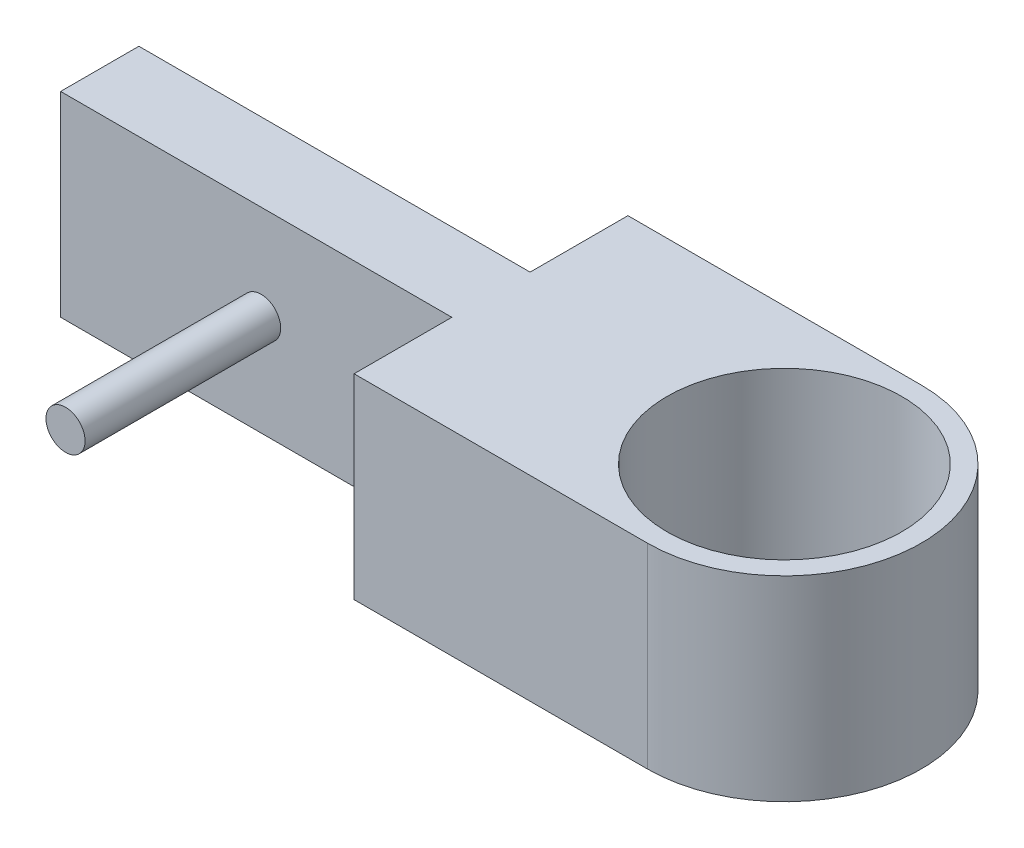
from build123d import *

# Parameters (mm, degrees)
CROQUIS2_R              = 6
SALIENTE_EXTRUIR3_DEPTH = 10
CROQUIS9_R              = 1
SALIENTE_EXTRUIR6_DEPTH = 10


with BuildPart() as part:
    # Croquis2 → Saliente-Extruir3 (new body)
    with BuildSketch(Plane(origin=(0, 0, 0), x_dir=(1, 0, 0), z_dir=(0, 1, 0))):
        with BuildLine():
            Line((-56.772722473, 15.301893186), (-41.772722473, 15.301893186))
            ThreePointArc((-41.772722473, 15.301893186), (-34.772722473, 22.301893186), (-41.772722473, 29.301893186))
            Line((-41.772722473, 29.301893186), (-56.772722473, 29.301893186))
            Line((-56.772722473, 29.301893186), (-56.772722473, 24.301893186))
            Line((-56.772722473, 24.301893186), (-76.772722473, 24.301893186))
            Line((-76.772722473, 24.301893186), (-76.772722473, 20.301893186))
            Line((-76.772722473, 20.301893186), (-56.772722473, 20.301893186))
            Line((-56.772722473, 20.301893186), (-56.772722473, 15.301893186))
        make_face()
        with Locations((-41.772722473, 22.301893186)):
            Circle(CROQUIS2_R, mode=Mode.SUBTRACT)
    extrude(amount=SALIENTE_EXTRUIR3_DEPTH)

    # Croquis9 → Saliente-Extruir6 (add)
    with BuildSketch(Plane.XY.offset(-20.301893186)):
        with Locations((-66.52258031, 5.145347446)):
            Circle(CROQUIS9_R)
    extrude(amount=SALIENTE_EXTRUIR6_DEPTH)


solid = part.part
